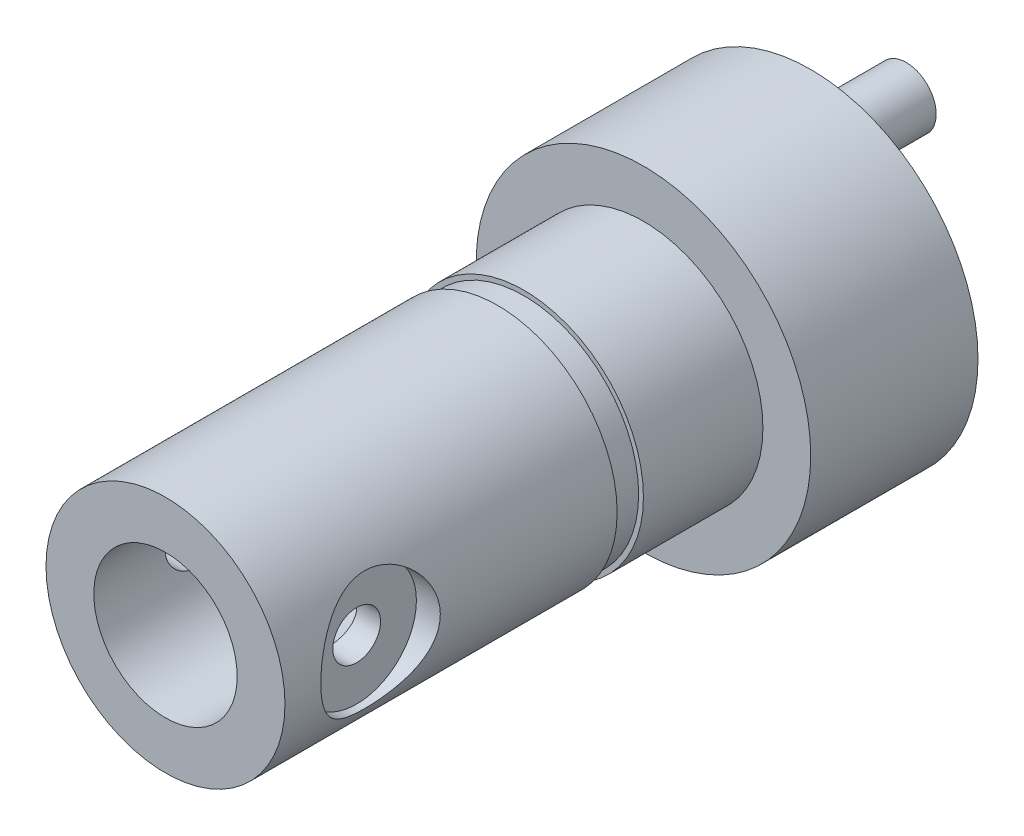
from build123d import *

# Parameters (mm, degrees)
SKETCH1_R           = 7
BOSS_EXTRUDE1_DEPTH = 7
SKETCH2_R           = 5
BOSS_EXTRUDE2_DEPTH = 20
SKETCH3_R           = 6
SKETCH3_R_2         = 4.8
CUT_EXTRUDE1_DEPTH  = 1.1
SKETCH4_R           = 1.25
BOSS_EXTRUDE3_DEPTH = 4
SKETCH5_R           = 1
CUT_EXTRUDE2_DEPTH  = 13
SKETCH6_R           = 2.5
CUT_EXTRUDE3_DEPTH  = 1
SKETCH7_R           = 3
CUT_EXTRUDE4_DEPTH  = 8


with BuildPart() as part:
    # Sketch1 → Boss-Extrude1 (new body)
    with BuildSketch(Plane.XY):
        Circle(SKETCH1_R)
    extrude(amount=-BOSS_EXTRUDE1_DEPTH)

    # Sketch2 → Boss-Extrude2 (add)
    with BuildSketch(Plane.XY):
        Circle(SKETCH2_R)
    extrude(amount=BOSS_EXTRUDE2_DEPTH)

    # Sketch3 → Cut-Extrude1 (cut)
    with BuildSketch(Plane.XY.offset(5)):
        Circle(SKETCH3_R)
        Circle(SKETCH3_R_2, mode=Mode.SUBTRACT)
    extrude(amount=CUT_EXTRUDE1_DEPTH, mode=Mode.SUBTRACT)

    # Sketch4 → Boss-Extrude3 (add)
    with BuildSketch(Plane(origin=(0, 0, -7), x_dir=(-1, 0, 0), z_dir=(0, 0, -1))):
        with Locations((0, 4)):
            Circle(SKETCH4_R)
    extrude(amount=BOSS_EXTRUDE3_DEPTH)

    # Sketch5 → Cut-Extrude2 (cut, through all)
    with BuildSketch(Plane(origin=(5, 0, 0), x_dir=(0, 0, -1), z_dir=(1, 0, 0))):
        with Locations((-16, 0)):
            Circle(SKETCH5_R)
    extrude(amount=-CUT_EXTRUDE2_DEPTH, mode=Mode.SUBTRACT)

    # Sketch6 → Cut-Extrude3 (cut)
    with BuildSketch(Plane(origin=(5, 0, 0), x_dir=(0, 0, -1), z_dir=(1, 0, 0))):
        with Locations((-16, 0)):
            Circle(SKETCH6_R)
    cut_extrude3 = extrude(amount=-CUT_EXTRUDE3_DEPTH, mode=Mode.SUBTRACT)

    # Mirror1: Cut-Extrude3 across plane
    add(cut_extrude3.mirror(Plane(origin=(0, 0, 0), x_dir=(0, 0, 1), z_dir=(1, 0, 0))), mode=Mode.SUBTRACT)

    # Sketch7 → Cut-Extrude4 (cut)
    with BuildSketch(Plane.XY.offset(20)):
        Circle(SKETCH7_R)
    extrude(amount=-CUT_EXTRUDE4_DEPTH, mode=Mode.SUBTRACT)


solid = part.part
